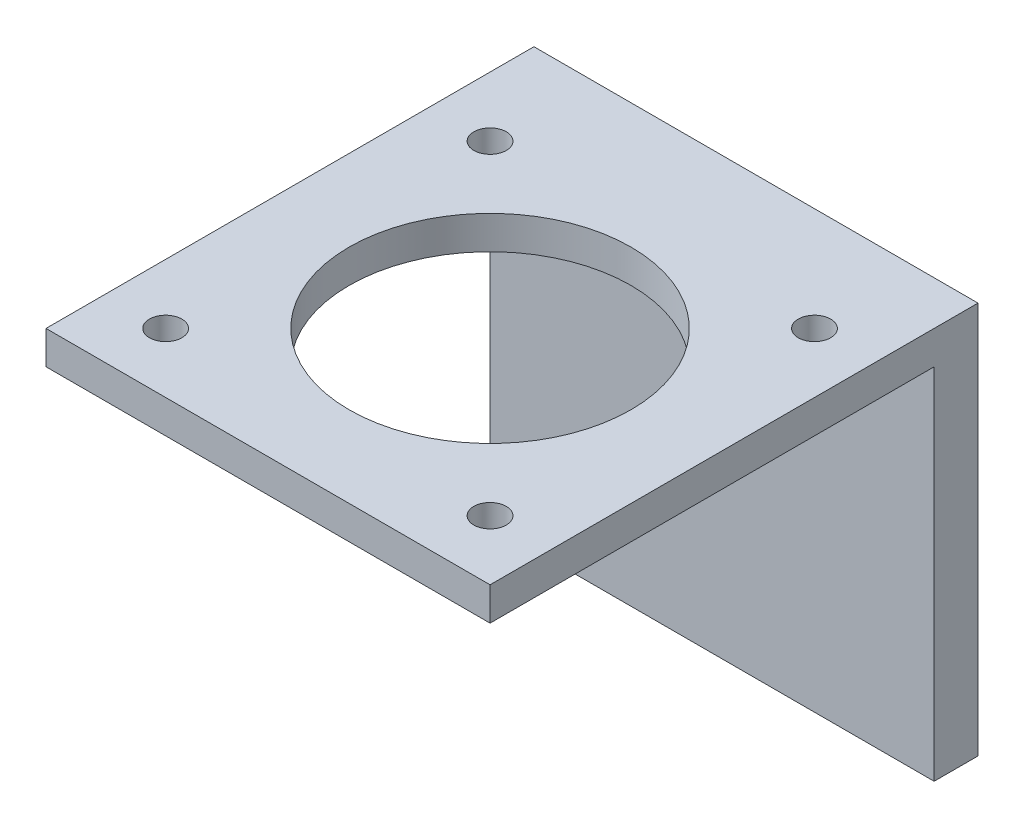
from build123d import *

# Parameters (mm, degrees)
SKETCH1_W           = 42.418
SKETCH1_H           = 42.418
SKETCH1_R           = 1.5494
SKETCH1_R_2         = 13.462
BOSS_EXTRUDE1_DEPTH = 3.175
SKETCH3_W           = 42.418
SKETCH3_H           = 4.191
BOSS_EXTRUDE2_DEPTH = 37.465


with BuildPart() as part:
    # Sketch1 → Boss-Extrude1 (new body)
    with BuildSketch(Plane(origin=(0, 0, 0), x_dir=(1, 0, 0), z_dir=(0, 1, 0))):
        Rectangle(SKETCH1_W, SKETCH1_H)
        with Locations((15.494, 15.494)):
            Circle(SKETCH1_R, mode=Mode.SUBTRACT)
        with Locations((-15.494, 15.494)):
            Circle(SKETCH1_R, mode=Mode.SUBTRACT)
        with Locations((15.494, -15.494)):
            Circle(SKETCH1_R, mode=Mode.SUBTRACT)
        with Locations((-15.494, -15.494)):
            Circle(SKETCH1_R, mode=Mode.SUBTRACT)
        Circle(SKETCH1_R_2, mode=Mode.SUBTRACT)
    extrude(amount=BOSS_EXTRUDE1_DEPTH)

    # Sketch3 → Boss-Extrude2 (add)
    with BuildSketch(Plane(origin=(0, 3.175, 0), x_dir=(1, 0, 0), z_dir=(0, 1, 0))):
        with Locations((0, 23.3045)):
            Rectangle(SKETCH3_W, SKETCH3_H)
    extrude(amount=-BOSS_EXTRUDE2_DEPTH)


solid = part.part
